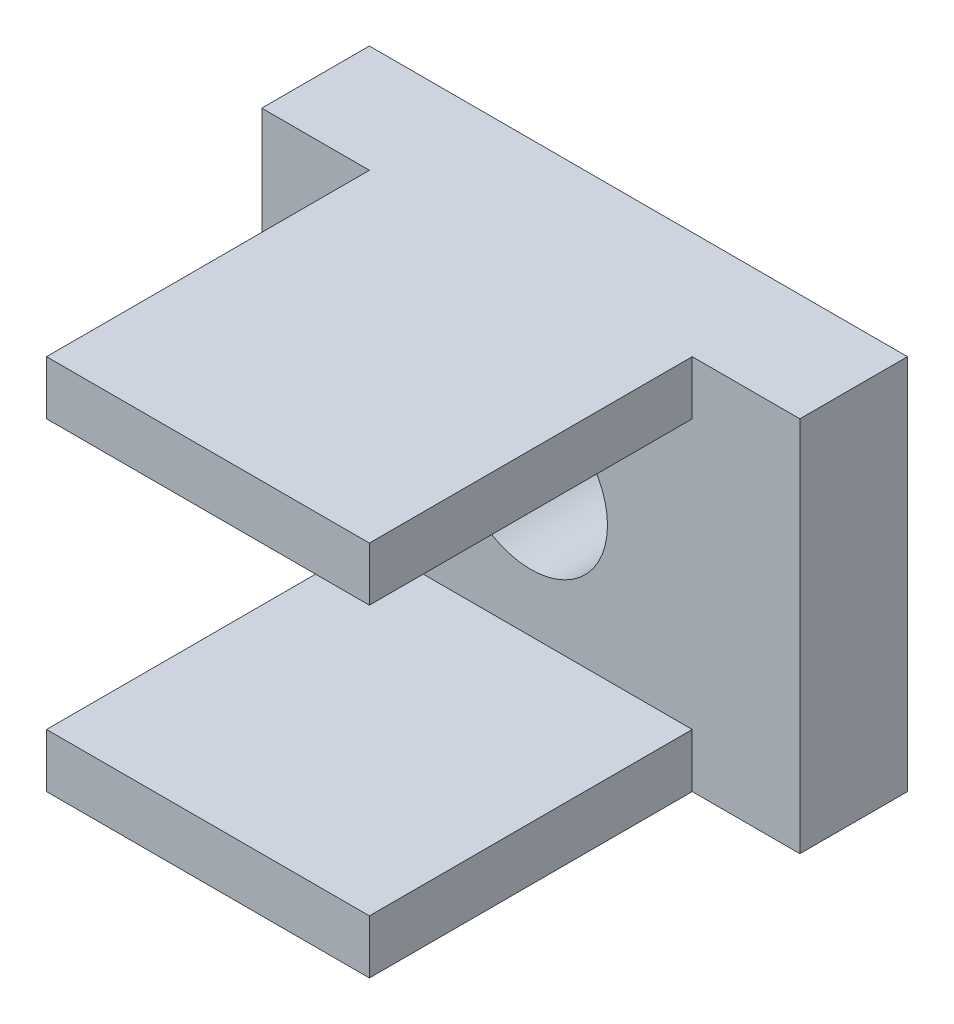
from build123d import *

# Parameters (mm, degrees)
SKETCH1_W           = 10
SKETCH1_H           = 7
SKETCH1_R           = 1.425
BOSS_EXTRUDE1_DEPTH = 2
SKETCH3_W           = 6
SKETCH3_H           = 1
BOSS_EXTRUDE2_DEPTH = 6


with BuildPart() as part:
    # Sketch1 → Boss-Extrude1 (new body)
    with BuildSketch(Plane.XY):
        Rectangle(SKETCH1_W, SKETCH1_H)
        Circle(SKETCH1_R, mode=Mode.SUBTRACT)
    extrude(amount=BOSS_EXTRUDE1_DEPTH)

    # Sketch3 → Boss-Extrude2 (add)
    with BuildSketch(Plane.XY.offset(2)):
        with Locations((0, 3)):
            Rectangle(SKETCH3_W, SKETCH3_H)
    boss_extrude2 = extrude(amount=BOSS_EXTRUDE2_DEPTH)

    # Mirror1: Boss-Extrude2 across plane
    add(boss_extrude2.mirror(Plane.ZX))


solid = part.part
